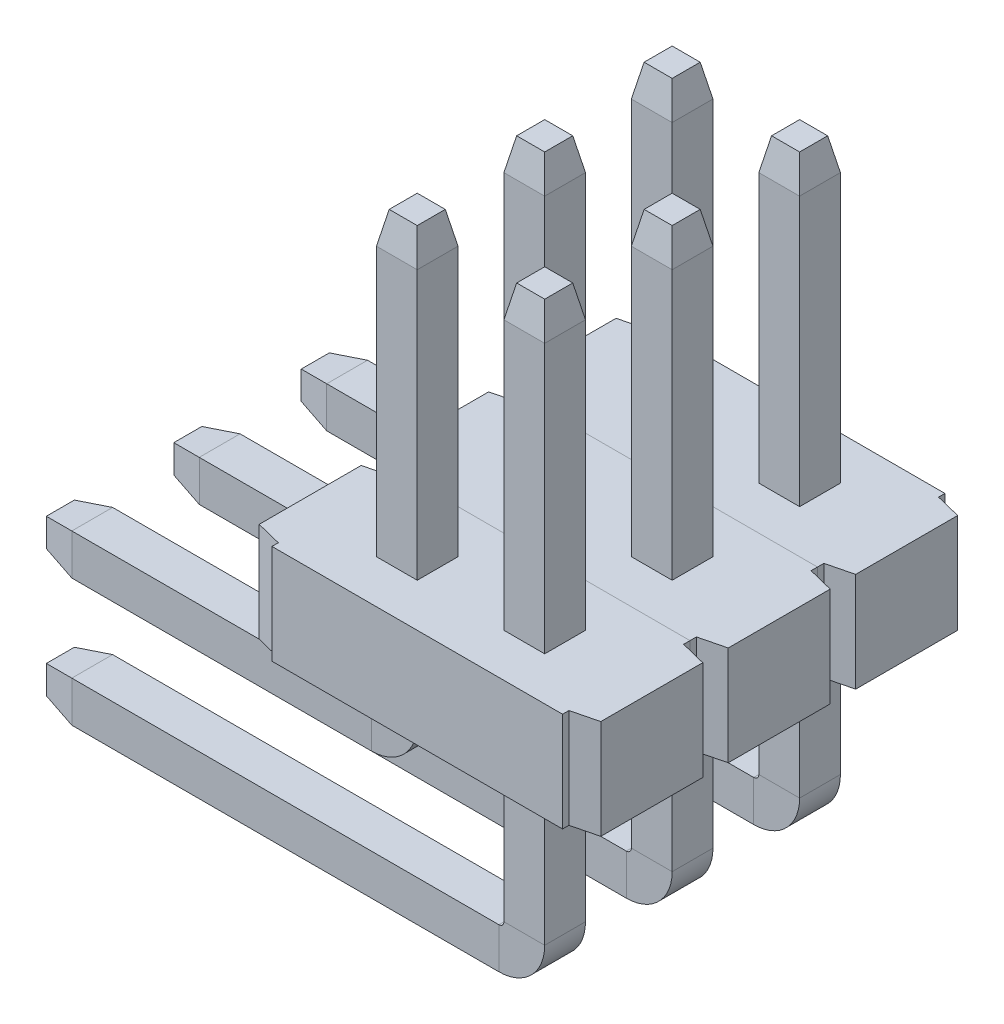
from build123d import *

# Parameters (mm, degrees)
BOSS_EXTRUDE2_DEPTH   = 0.9906
SKETCH5_W             = 0.4064
SKETCH5_H             = 0.4064
SKETCH6_W             = 0.4064
SKETCH6_H             = 0.4064
CHAMFER1_SIZE         = 0.0635
CHAMFER1_SIZE2        = 0.3175
CHAMFER1_PART_2_SIZE  = 0.0635
CHAMFER1_PART_2_SIZE2 = 0.3175
CHAMFER2_SIZE         = 0.3175
CHAMFER2_SIZE2        = 0.0635
CHAMFER2_PART_2_SIZE  = 0.3175
CHAMFER2_PART_2_SIZE2 = 0.0635
CHAMFER2_PART_3_SIZE  = 0.3175
CHAMFER2_PART_3_SIZE2 = 0.0635
CHAMFER2_PART_4_SIZE  = 0.3175
CHAMFER2_PART_4_SIZE2 = 0.0635
CHAMFER2_PART_5_SIZE  = 0.3175
CHAMFER2_PART_5_SIZE2 = 0.0635
CHAMFER2_PART_6_SIZE  = 0.3175
CHAMFER2_PART_6_SIZE2 = 0.0635
CHAMFER2_PART_7_SIZE  = 0.3175
CHAMFER2_PART_7_SIZE2 = 0.0635
CHAMFER2_PART_8_SIZE  = 0.3175
CHAMFER2_PART_8_SIZE2 = 0.0635
LPATTERN1_COUNT       = 3
LPATTERN1_PITCH       = 1.27


with BuildPart() as part:
    # Sketch1 → Boss-Extrude2 (new body)
    with BuildSketch(Plane(origin=(0, 0, 0), x_dir=(1, 0, 0), z_dir=(0, 1, 0))):
        Polygon((-1.7018, -0.508), (-1.4478, -0.5715), (-1.4478, -0.635), (1.4478, -0.635), (1.4478, -0.5715), (1.7018, -0.508), (1.7018, 0.508), (1.4478, 0.5715), (1.4478, 0.635), (-1.4478, 0.635), (-1.4478, 0.5715), (-1.7018, 0.508), align=None)
    extrude(amount=BOSS_EXTRUDE2_DEPTH)

    # Sweep5: sweep along a path in Sketch2
    with BuildLine(Plane.XY) as sweep5_path:
        Line((-0.635, 3.9878), (-0.635, 0.9906))
        Line((-0.635, 0.9906), (-0.635, -0.254))
        ThreePointArc((-0.635, -0.254), (-0.709395, -0.433605), (-0.889, -0.508))
        Line((-0.889, -0.508), (-4.191, -0.508))
    # Sketch5 → Sweep5 (sweep)
    with BuildSketch(Plane(origin=(0, 3.9878, 0), x_dir=(1, 0, 0), z_dir=(0, 1, 0))):
        with Locations((-0.635, 0)):
            Rectangle(SKETCH5_W, SKETCH5_H)
    sweep(path=sweep5_path.line)

    # Sweep6: sweep along a path in Sketch7
    with BuildLine(Plane.XY) as sweep6_path:
        Line((-4.191, -1.778), (0.381, -1.778))
        ThreePointArc((0.381, -1.778), (0.560605, -1.703605), (0.635, -1.524))
        Line((0.635, -1.524), (0.635, 0.9906))
        Line((0.635, 0.9906), (0.635, 3.9878))
    # Sketch6 → Sweep6 (sweep)
    with BuildSketch(Plane(origin=(0, 3.9878, 0), x_dir=(1, 0, 0), z_dir=(0, 1, 0))):
        with Locations((0.635, 0)):
            Rectangle(SKETCH6_W, SKETCH6_H)
    sweep(path=sweep6_path.line)

    # Chamfer1
    chamfer1_edges = [part.edges().sort_by_distance(p)[0] for p in [
        (-0.635, 3.9878, -0.2032),
        (-0.4318, 3.9878, 0),
        (-0.635, 3.9878, 0.2032),
        (-0.8382, 3.9878, 0),
    ]]
    chamfer1_side = [part.faces().sort_by_distance(p)[0] for p in [
        (-0.635, 3.9878, 0),
    ]]
    chamfer(chamfer1_edges, length=CHAMFER1_SIZE, length2=CHAMFER1_SIZE2, reference=chamfer1_side[0])

    # Chamfer1 part 2
    chamfer1_part_2_edges = [part.edges().sort_by_distance(p)[0] for p in [
        (-4.191, -1.9812, 0),
        (-4.191, -1.778, -0.2032),
        (-4.191, -1.5748, 0),
        (-4.191, -1.778, 0.2032),
    ]]
    chamfer1_part_2_side = [part.faces().sort_by_distance(p)[0] for p in [
        (-4.191, -1.778, 0),
    ]]
    chamfer(chamfer1_part_2_edges, length=CHAMFER1_PART_2_SIZE, length2=CHAMFER1_PART_2_SIZE2, reference=chamfer1_part_2_side[0])

    # Chamfer2
    chamfer2_edges = [part.edges().sort_by_distance(p)[0] for p in [
        (-4.191, -0.508, -0.2032),
    ]]
    chamfer2_side = [part.faces().sort_by_distance(p)[0] for p in [
        (-2.231309, -0.4777, -0.2032),
    ]]
    chamfer(chamfer2_edges, length=CHAMFER2_SIZE, length2=CHAMFER2_SIZE2, reference=chamfer2_side[0])

    # Chamfer2 part 2
    chamfer2_part_2_edges = [part.edges().sort_by_distance(p)[0] for p in [
        (-4.191, -0.7112, 0),
    ]]
    chamfer2_part_2_side = [part.faces().sort_by_distance(p)[0] for p in [
        (-2.54, -0.7112, 0),
    ]]
    chamfer(chamfer2_part_2_edges, length=CHAMFER2_PART_2_SIZE, length2=CHAMFER2_PART_2_SIZE2, reference=chamfer2_part_2_side[0])

    # Chamfer2 part 3
    chamfer2_part_3_edges = [part.edges().sort_by_distance(p)[0] for p in [
        (-4.191, -0.508, 0.2032),
    ]]
    chamfer2_part_3_side = [part.faces().sort_by_distance(p)[0] for p in [
        (-2.231309, -0.4777, 0.2032),
    ]]
    chamfer(chamfer2_part_3_edges, length=CHAMFER2_PART_3_SIZE, length2=CHAMFER2_PART_3_SIZE2, reference=chamfer2_part_3_side[0])

    # Chamfer2 part 4
    chamfer2_part_4_edges = [part.edges().sort_by_distance(p)[0] for p in [
        (-4.191, -0.3048, 0),
    ]]
    chamfer2_part_4_side = [part.faces().sort_by_distance(p)[0] for p in [
        (-2.54, -0.3048, 0),
    ]]
    chamfer(chamfer2_part_4_edges, length=CHAMFER2_PART_4_SIZE, length2=CHAMFER2_PART_4_SIZE2, reference=chamfer2_part_4_side[0])

    # Chamfer2 part 5
    chamfer2_part_5_edges = [part.edges().sort_by_distance(p)[0] for p in [
        (0.8382, 3.9878, 0),
    ]]
    chamfer2_part_5_side = [part.faces().sort_by_distance(p)[0] for p in [
        (0.8382, 2.4892, 0),
    ]]
    chamfer(chamfer2_part_5_edges, length=CHAMFER2_PART_5_SIZE, length2=CHAMFER2_PART_5_SIZE2, reference=chamfer2_part_5_side[0])

    # Chamfer2 part 6
    chamfer2_part_6_edges = [part.edges().sort_by_distance(p)[0] for p in [
        (0.635, 3.9878, -0.2032),
    ]]
    chamfer2_part_6_side = [part.faces().sort_by_distance(p)[0] for p in [
        (0.635, 2.4892, -0.2032),
    ]]
    chamfer(chamfer2_part_6_edges, length=CHAMFER2_PART_6_SIZE, length2=CHAMFER2_PART_6_SIZE2, reference=chamfer2_part_6_side[0])

    # Chamfer2 part 7
    chamfer2_part_7_edges = [part.edges().sort_by_distance(p)[0] for p in [
        (0.4318, 3.9878, 0),
    ]]
    chamfer2_part_7_side = [part.faces().sort_by_distance(p)[0] for p in [
        (0.4318, 2.4892, 0),
    ]]
    chamfer(chamfer2_part_7_edges, length=CHAMFER2_PART_7_SIZE, length2=CHAMFER2_PART_7_SIZE2, reference=chamfer2_part_7_side[0])

    # Chamfer2 part 8
    chamfer2_part_8_edges = [part.edges().sort_by_distance(p)[0] for p in [
        (0.635, 3.9878, 0.2032),
    ]]
    chamfer2_part_8_side = [part.faces().sort_by_distance(p)[0] for p in [
        (0.635, 2.4892, 0.2032),
    ]]
    chamfer(chamfer2_part_8_edges, length=CHAMFER2_PART_8_SIZE, length2=CHAMFER2_PART_8_SIZE2, reference=chamfer2_part_8_side[0])


with BuildPart() as lpattern1_1:
    # LPattern1: pattern copy
    add(part.part.moved(Location(Vector(0, 0, -1) * (1 * LPATTERN1_PITCH))))


with BuildPart() as lpattern1_2:
    # LPattern1: pattern copy
    add(part.part.moved(Location(Vector(0, 0, -1) * (2 * LPATTERN1_PITCH))))


solid = Compound([part.part, lpattern1_1.part, lpattern1_2.part])
